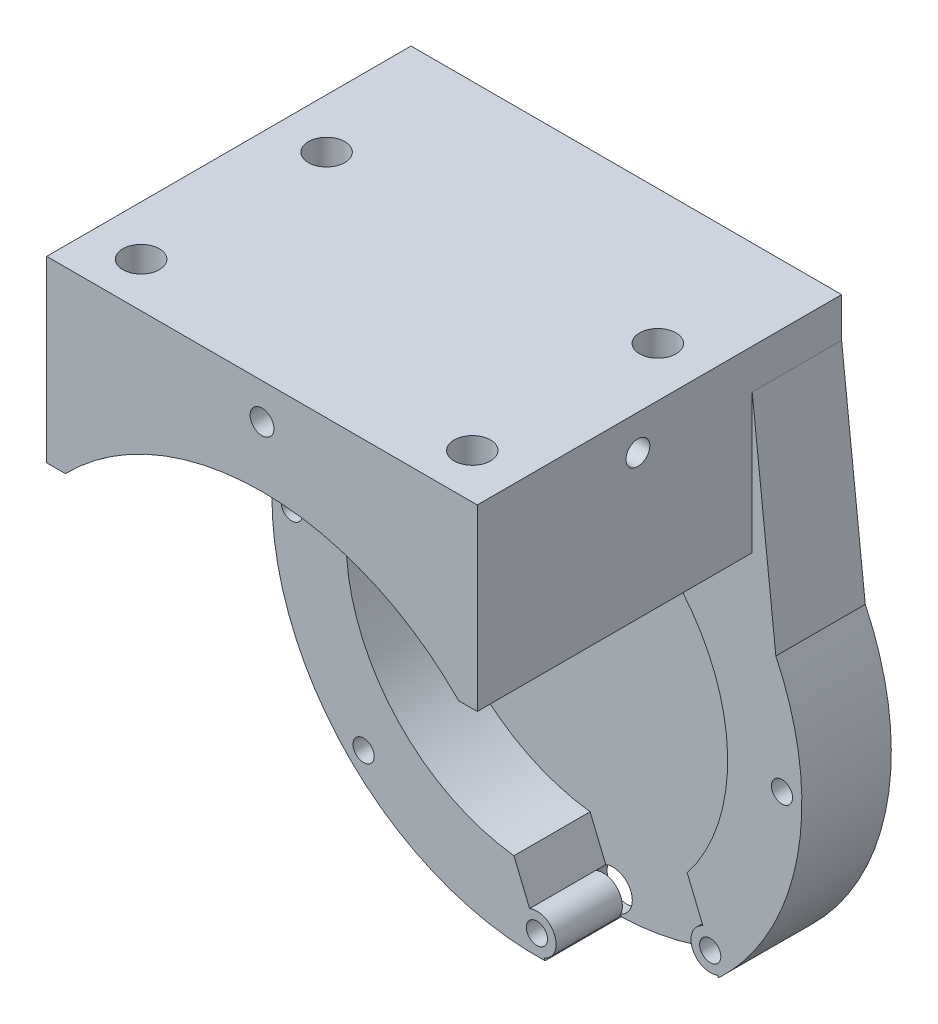
from build123d import *

# Parameters (mm, degrees)
EXTRUDE_1_DEPTH          = 13.5
SKETCH_2_R               = 28.8
CUT_EXTRUDE_1_DEPTH      = 11.5
SKETCH_3_R               = 1.6
CUT_EXTRUDE_2_DEPTH      = 14.5
SKETCH_6_R               = 2.9
CUT_EXTRUDE_6_DEPTH      = 3.5
PATTERN_CIRCULAR_3_COUNT = 8
EXTRUDE_2_DEPTH          = 10
EXTRUDE_2_DEPTH_BACK     = 11
CUT_EXTRUDE_7_DEPTH      = 42.5
SKETCH_25_W              = 65
SKETCH_25_H              = 55
EXTRUDE_4_DEPTH          = 6
SKETCH_33_R              = 2.75
CUT_EXTRUDE_14_DEPTH     = 97
SKETCH_34_R              = 5
CUT_EXTRUDE_15_DEPTH     = 87
CUT_EXTRUDE_16_DEPTH     = 54.0000001
SKETCH_40_R              = 1.8
CUT_EXTRUDE_18_DEPTH     = 12
SKETCH_41_R              = 1.8
CUT_EXTRUDE_19_DEPTH     = 12
SKETCH_42_R              = 1.8
CUT_EXTRUDE_20_DEPTH     = 12
SKETCH_43_R              = 1.8
CUT_EXTRUDE_21_DEPTH     = 12


with BuildPart() as part:
    # 草图1 → 凸台-拉伸1 (new body)
    with BuildSketch(Plane.XY.offset(-14)):
        with BuildLine():
            Line((36.070726916, 17.288801572), (32.5, 50))
            Line((32.5, 50), (-32.5, 50))
            Line((-32.5, 50), (-36.070726916, 17.288801572))
            ThreePointArc((-36.070726916, 17.288801572), (0, -40), (36.070726916, 17.288801572))
        make_face()
    extrude(amount=-EXTRUDE_1_DEPTH)

    # 草图2 → 切除-拉伸1 (cut)
    with BuildSketch(Plane.XY.offset(-14)):
        Circle(SKETCH_2_R)
    extrude(amount=-CUT_EXTRUDE_1_DEPTH, mode=Mode.SUBTRACT)

    # 草图3 → 切除-拉伸2 (cut, through all)
    with BuildSketch(Plane(origin=(0, 0, -27.5), x_dir=(-1, 0, 0), z_dir=(0, 0, -1))):
        with Locations((0, 37)):
            Circle(SKETCH_3_R)
    cut_extrude_2 = extrude(amount=-CUT_EXTRUDE_2_DEPTH, mode=Mode.SUBTRACT)

    # 草图6 → 切除-拉伸6 (cut)
    with BuildSketch(Plane(origin=(0, 0, -27.5), x_dir=(-1, 0, 0), z_dir=(0, 0, -1))):
        with Locations((0, 37)):
            Circle(SKETCH_6_R)
        with Locations((26.162950904, 26.162950904)):
            Circle(SKETCH_6_R)
        with Locations((37, 0)):
            Circle(SKETCH_6_R)
        with Locations((26.162950904, -26.162950904)):
            Circle(SKETCH_6_R)
        with Locations((-37, 0)):
            Circle(SKETCH_6_R)
        with Locations((-26.162950904, 26.162950904)):
            Circle(SKETCH_6_R)
        with Locations((0, -37)):
            Circle(SKETCH_6_R)
        with Locations((-26.162950904, -26.162950904)):
            Circle(SKETCH_6_R)
    extrude(amount=-CUT_EXTRUDE_6_DEPTH, mode=Mode.SUBTRACT)

    # 阵列(圆周)3: 切除-拉伸2 ×8 about axis
    pattern_circular_3_axis = Axis((0, 0, 0), (0, 0, 1))
    for i in range(1, PATTERN_CIRCULAR_3_COUNT):
        add(cut_extrude_2.rotate(pattern_circular_3_axis, i * 360 / PATTERN_CIRCULAR_3_COUNT), mode=Mode.SUBTRACT)



with BuildPart() as body_2:
    # 草图7 → 凸台-拉伸2 (new body, two sides)
    with BuildSketch(Plane(origin=(0, 40, 0), x_dir=(1, 0, 0), z_dir=(0, 1, 0))) as extrude_2_sk:
        Polygon((-32.5, 0), (-32.5, 16.283385264), (-32.5, 27.5), (-5.850968587, 27.5), (-5.850968587, 14), (5.653955786, 14), (5.653955786, 27.5), (32.5, 27.5), (32.5, 16.283385264), (32.5, 0), (32.5, -27.5), (0, -27.5), (-32.5, -27.5), align=None)
    extrude(amount=EXTRUDE_2_DEPTH)
    extrude(extrude_2_sk.sketch, amount=-EXTRUDE_2_DEPTH_BACK)

    # 草图9 → 切除-拉伸7 (cut, through all)
    with BuildSketch(Plane.XY.offset(-14)):
        with BuildLine():
            Line((-31.306275756, 27.242743956), (31.306275756, 27.242743956))
            ThreePointArc((31.306275756, 27.242743956), (0, 41.5), (-31.306275756, 27.242743956))
        make_face()
    extrude(amount=CUT_EXTRUDE_7_DEPTH, mode=Mode.SUBTRACT)


with BuildPart() as part_1:
    add(part.part)

    add(body_2.part)  # 凸台-拉伸4 merges body 2
    # 草图25 → 凸台-拉伸4 (add)
    with BuildSketch(Plane(origin=(0, 50, 0), x_dir=(1, 0, 0), z_dir=(0, 1, 0))):
        Rectangle(SKETCH_25_W, SKETCH_25_H)
    extrude(amount=EXTRUDE_4_DEPTH)

    # 草图33 → 切除-拉伸14 (cut, through all)
    with BuildSketch(Plane(origin=(0, 56, 0), x_dir=(1, 0, 0), z_dir=(0, 1, 0))):
        with Locations((-25, 7.25)):
            Circle(SKETCH_33_R)
        with Locations((25, 7.25)):
            Circle(SKETCH_33_R)
        with Locations((-25, -20.75)):
            Circle(SKETCH_33_R)
        with Locations((25, -20.75)):
            Circle(SKETCH_33_R)
    extrude(amount=-CUT_EXTRUDE_14_DEPTH, mode=Mode.SUBTRACT)

    # 草图34 → 切除-拉伸15 (cut, through all)
    with BuildSketch(Plane(origin=(0, 46, 0), x_dir=(1, 0, 0), z_dir=(0, 1, 0))):
        with Locations((-25, 7.25)):
            Circle(SKETCH_34_R)
        with Locations((25, 7.25)):
            Circle(SKETCH_34_R)
        with Locations((-25, -20.75)):
            Circle(SKETCH_34_R)
        with Locations((25, -20.75)):
            Circle(SKETCH_34_R)
    extrude(amount=-CUT_EXTRUDE_15_DEPTH, mode=Mode.SUBTRACT)

    # 草图35 → 切除-拉伸16 (cut, through all)
    with BuildSketch(Plane.XY.offset(-25.5)):
        with BuildLine():
            Line((-5.482310635, -23.69583549), (20.700351605, -12.906620763))
            Line((20.700351605, -12.906620763), (25.058065646, -23.48167722))
            ThreePointArc((25.058065646, -23.48167722), (23.48167722, -27.267836162), (27.267836162, -28.844224588))
            Line((27.267836162, -28.844224588), (28.638176696, -32.169690276))
            Line((28.638176696, -32.169690276), (2.465370124, -42.982822188))
            Line((2.465370124, -42.982822188), (1.104885258, -39.681273684))
            ThreePointArc((1.104885258, -39.681273684), (2.681273684, -35.895114742), (-1.104885258, -34.318726316))
            Line((-1.104885258, -34.318726316), (-5.482310635, -23.69583549))
        make_face()
    extrude(amount=CUT_EXTRUDE_16_DEPTH, mode=Mode.SUBTRACT)

    # 草图40 → 切除-拉伸18 (cut)
    with BuildSketch(Plane.XY.offset(27.5)):
        with Locations((0, 50.608642373)):
            Circle(SKETCH_40_R)
    extrude(amount=-CUT_EXTRUDE_18_DEPTH, mode=Mode.SUBTRACT)

    # 草图41 → 切除-拉伸19 (cut)
    with BuildSketch(Plane(origin=(-37.510987458, 4.09466785, 0), x_dir=(0, 0, 1), z_dir=(-0.99409486, 0.108514559, 0))):
        with Locations((-20.75, 29.979930787)):
            Circle(SKETCH_41_R)
    extrude(amount=-CUT_EXTRUDE_19_DEPTH, mode=Mode.SUBTRACT)

    # 草图42 → 切除-拉伸20 (cut)
    with BuildSketch(Plane(origin=(32.5, 0, 0), x_dir=(0, 0, -1), z_dir=(1, 0, 0))):
        with Locations((-3.254490718, 50.718137082)):
            Circle(SKETCH_42_R)
    extrude(amount=-CUT_EXTRUDE_20_DEPTH, mode=Mode.SUBTRACT)

    # 草图43 → 切除-拉伸21 (cut)
    with BuildSketch(Plane.ZY.offset(32.5)):
        with Locations((2.489697323, 51.600552718)):
            Circle(SKETCH_43_R)
    extrude(amount=-CUT_EXTRUDE_21_DEPTH, mode=Mode.SUBTRACT)


solid = part_1.part
